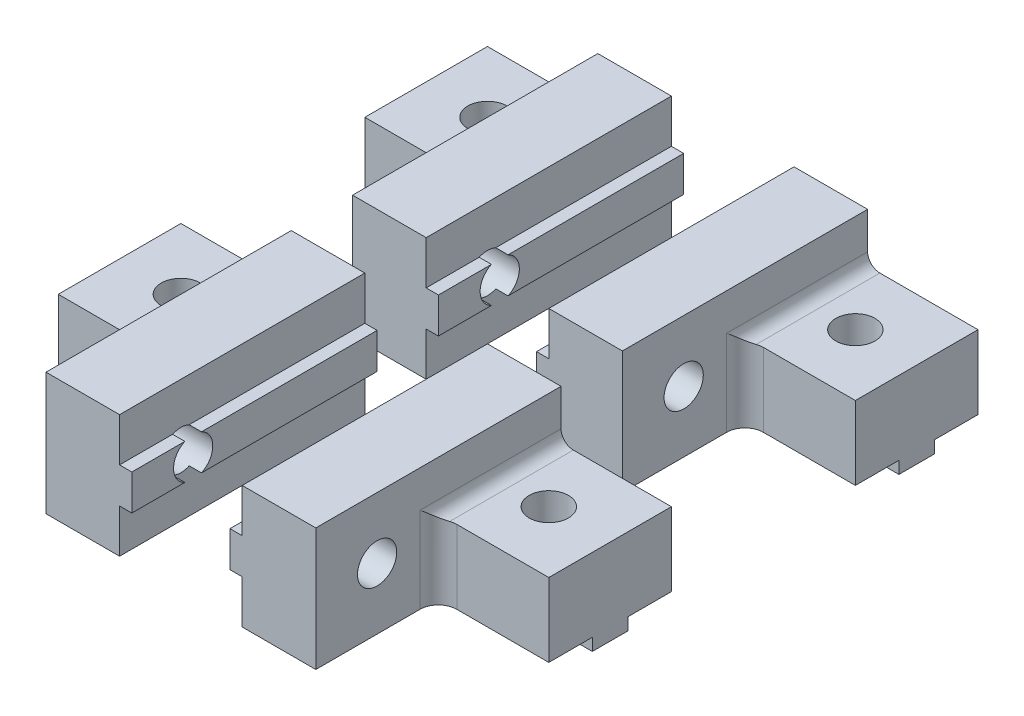
from build123d import *

# Parameters (mm, degrees)
MAIN_DEPTH                   = 20
ESQUISSE4_W                  = 20
ESQUISSE4_H                  = 2.9
VERTICALGUIDANCE_DEPTH       = 1
VERTICALHOLE_DEPTH           = 27.925824036
VERTICALHOLE_DEPTH_BACK      = 27.925824036
ESQUISSE2_R                  = 1.6
ESQUISSE5_W                  = 15
ESQUISSE5_H                  = 2.9
HORIZONTALGUIDANCE_DEPTH     = 1
HORIZONTALHOLE_DEPTH         = 26.961510106
HORIZONTALHOLE_DEPTH_BACK    = 26.961510106
ESQUISSE3_R                  = 1.6
ENL_V_MAT_EXTRU_4_DEPTH      = 26.961510106
ENL_V_MAT_EXTRU_4_DEPTH_BACK = 26.961510106
ESQUISSE9_W                  = 9
ESQUISSE9_H                  = 10
CONG_2_R                     = 1.5
R_P_TITION_LIN_AIRE1_COUNT   = 2
R_P_TITION_LIN_AIRE1_PITCH   = 25


with BuildPart() as part:
    # Esquisse1 → Main (new body)
    with BuildSketch(Plane.XY):
        with BuildLine():
            Line((0, 0), (15, 0))
            Line((15, 0), (15, 6))
            Line((15, 6), (7, 6))
            ThreePointArc((7, 6), (6.292893219, 6.292893219), (6, 7))
            Line((6, 7), (6, 10))
            Line((6, 10), (0, 10))
            Line((0, 10), (0, 0))
        make_face()
    extrude(amount=MAIN_DEPTH)

    # Esquisse4 → VerticalGuidance (add)
    with BuildSketch(Plane.ZY):
        with Locations((10, 5)):
            Rectangle(ESQUISSE4_W, ESQUISSE4_H)
    extrude(amount=VERTICALGUIDANCE_DEPTH)

    # Esquisse2 → VerticalHole (cut, two sides: drawn at the far end of the back side and taken through both)
    with BuildSketch(Plane.ZY.offset(-VERTICALHOLE_DEPTH_BACK)):
        with Locations((15, 5)):
            Circle(ESQUISSE2_R)
    extrude(amount=VERTICALHOLE_DEPTH + VERTICALHOLE_DEPTH_BACK, mode=Mode.SUBTRACT)

    # Esquisse5 → HorizontalGuidance (add)
    with BuildSketch(Plane(origin=(0, 0, 0), x_dir=(-1, 0, 0), z_dir=(0, -1, 0))):
        with Locations((-7.5, -5)):
            Rectangle(ESQUISSE5_W, ESQUISSE5_H)
    extrude(amount=HORIZONTALGUIDANCE_DEPTH)

    # Esquisse3 → HorizontalHole (cut, two sides: drawn at the far end of the back side and taken through both)
    with BuildSketch(Plane.XZ.offset(-6).offset(-HORIZONTALHOLE_DEPTH_BACK)):
        with Locations((10, 5)):
            Circle(ESQUISSE3_R)
    extrude(amount=HORIZONTALHOLE_DEPTH + HORIZONTALHOLE_DEPTH_BACK, mode=Mode.SUBTRACT)

    # Esquisse9 → Enlèv. mat.-Extru.4 (cut, two sides: drawn at the far end of the back side and taken through both)
    with BuildSketch(Plane(origin=(0, 6, 0), x_dir=(1, 0, 0), z_dir=(0, 1, 0)).offset(-ENL_V_MAT_EXTRU_4_DEPTH_BACK)):
        with Locations((10.5, -15)):
            Rectangle(ESQUISSE9_W, ESQUISSE9_H)
    extrude(amount=ENL_V_MAT_EXTRU_4_DEPTH + ENL_V_MAT_EXTRU_4_DEPTH_BACK, mode=Mode.SUBTRACT)

    # Congé2
    cong_2_edges = [part.edges().sort_by_distance(p)[0] for p in [
        (6, 3.5, 10),
    ]]
    fillet(cong_2_edges, radius=CONG_2_R)


with BuildPart() as r_p_tition_lin_aire1_1:
    # Répétition linéaire1: pattern copy
    add(part.part.moved(Location(Vector(0, 0, 1) * (1 * R_P_TITION_LIN_AIRE1_PITCH))))


with BuildPart() as body_3:
    # Symétrie3: mirrored copy
    add(r_p_tition_lin_aire1_1.part.mirror(Plane(origin=(-5, 0, 0), x_dir=(0, 0, 1), z_dir=(1, 0, 0))))


with BuildPart() as body_4:
    # Sym_trie3 2: mirrored copy
    add(part.part.mirror(Plane(origin=(-5, 0, 0), x_dir=(0, 0, 1), z_dir=(1, 0, 0))))


solid = Compound([part.part, r_p_tition_lin_aire1_1.part, body_3.part, body_4.part])
